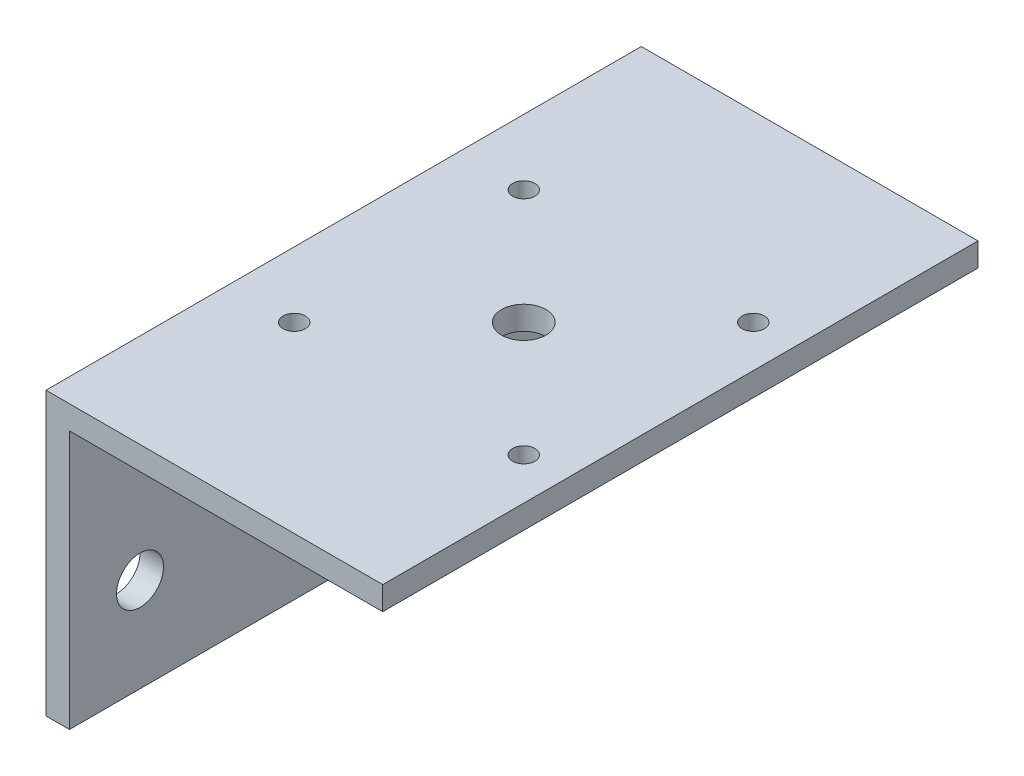
from build123d import *

# Parameters (mm, degrees)
BOSS_EXTRUDE1_DEPTH = 80.4
SKETCH2_R           = 3.175
CUT_EXTRUDE1_DEPTH  = 4.175
SKETCH3_R           = 1.5
SKETCH3_R_2         = 3
CUT_EXTRUDE2_DEPTH  = 39.1


with BuildPart() as part:
    # Sketch1 → Boss-Extrude1 (new body)
    with BuildSketch(Plane.XY):
        Polygon((0, 0), (3.175, 0), (3.175, 34.925), (45.475, 34.925), (45.475, 38.1), (0, 38.1), align=None)
    extrude(amount=BOSS_EXTRUDE1_DEPTH)

    # Sketch2 → Cut-Extrude1 (cut, through all)
    with BuildSketch(Plane(origin=(3.175, 0, 0), x_dir=(0, 0, -1), z_dir=(1, 0, 0))):
        with Locations((-70.875, 12.7)):
            Circle(SKETCH2_R)
        with Locations((-9.525, 12.7)):
            Circle(SKETCH2_R)
    extrude(amount=-CUT_EXTRUDE1_DEPTH, mode=Mode.SUBTRACT)

    # Sketch3 → Cut-Extrude2 (cut, through all)
    with BuildSketch(Plane(origin=(0, 38.1, 0), x_dir=(1, 0, 0), z_dir=(0, 1, 0))):
        with Locations((39.825, -55.7)):
            Circle(SKETCH3_R)
        with Locations((8.825, -55.7)):
            Circle(SKETCH3_R)
        with Locations((8.825, -24.7)):
            Circle(SKETCH3_R)
        with Locations((39.825, -24.7)):
            Circle(SKETCH3_R)
        with Locations((24.325, -40.2)):
            Circle(SKETCH3_R_2)
    extrude(amount=-CUT_EXTRUDE2_DEPTH, mode=Mode.SUBTRACT)


solid = part.part
